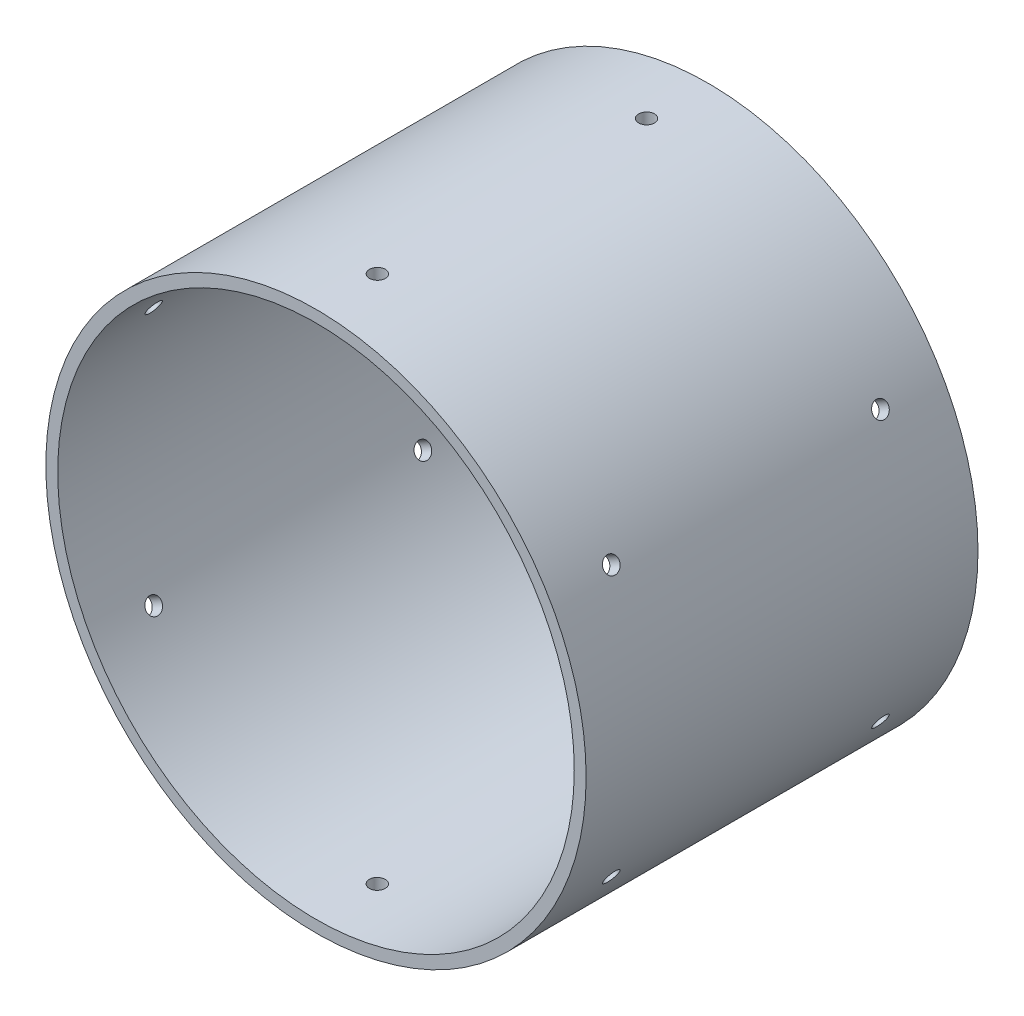
from build123d import *

# Parameters (mm, degrees)
SKETCH1_R               = 68.25
SKETCH1_R_2             = 65.25
BOSS_EXTRUDE1_DEPTH     = 99
SKETCH2_R               = 2
CUT_EXTRUDE1_DEPTH      = 44.106233808
CUT_EXTRUDE1_DEPTH_BACK = 144.356233808
SKETCH3_R               = 2
CUT_EXTRUDE2_DEPTH      = 19.1250001
CUT_EXTRUDE2_DEPTH_BACK = 119.3750001
SKETCH4_R               = 2
CUT_EXTRUDE3_DEPTH      = 48.356233952
CUT_EXTRUDE3_DEPTH_BACK = 140.106233952


with BuildPart() as part:
    # Sketch1 → Boss-Extrude1 (new body)
    with BuildSketch(Plane.XY):
        Circle(SKETCH1_R)
        Circle(SKETCH1_R_2, mode=Mode.SUBTRACT)
    extrude(amount=-BOSS_EXTRUDE1_DEPTH)

    # Sketch2 → Cut-Extrude1 (cut, two sides)
    with BuildSketch(Plane(origin=(41.534523365, -28.310095264, -87.5), x_dir=(0, 0, -1), z_dir=(0.866025404, -0.5, 0))) as cut_extrude1_sk:
        with Locations((-4, 3.75)):
            Circle(SKETCH2_R)
        with Locations((-72, 3.75)):
            Circle(SKETCH2_R)
    extrude(amount=CUT_EXTRUDE1_DEPTH, mode=Mode.SUBTRACT)
    extrude(cut_extrude1_sk.sketch, amount=-CUT_EXTRUDE1_DEPTH_BACK, mode=Mode.SUBTRACT)

    # Sketch3 → Cut-Extrude2 (cut, two sides)
    with BuildSketch(Plane(origin=(3.75, 50.125, -87.5), x_dir=(1, 0, 0), z_dir=(0, 1, 0))) as cut_extrude2_sk:
        with Locations((-3.75, -4)):
            Circle(SKETCH3_R)
        with Locations((-3.75, -72)):
            Circle(SKETCH3_R)
    extrude(amount=CUT_EXTRUDE2_DEPTH, mode=Mode.SUBTRACT)
    extrude(cut_extrude2_sk.sketch, amount=-CUT_EXTRUDE2_DEPTH_BACK, mode=Mode.SUBTRACT)

    # Sketch4 → Cut-Extrude3 (cut, two sides)
    with BuildSketch(Plane(origin=(41.603915399, 19.689904736, -87.5), x_dir=(0, 0, -1), z_dir=(0.866025404, 0.5, 0))) as cut_extrude3_sk:
        with Locations((-4, 3.75)):
            Circle(SKETCH4_R)
        with Locations((-72, 3.75)):
            Circle(SKETCH4_R)
    extrude(amount=CUT_EXTRUDE3_DEPTH, mode=Mode.SUBTRACT)
    extrude(cut_extrude3_sk.sketch, amount=-CUT_EXTRUDE3_DEPTH_BACK, mode=Mode.SUBTRACT)


solid = part.part
